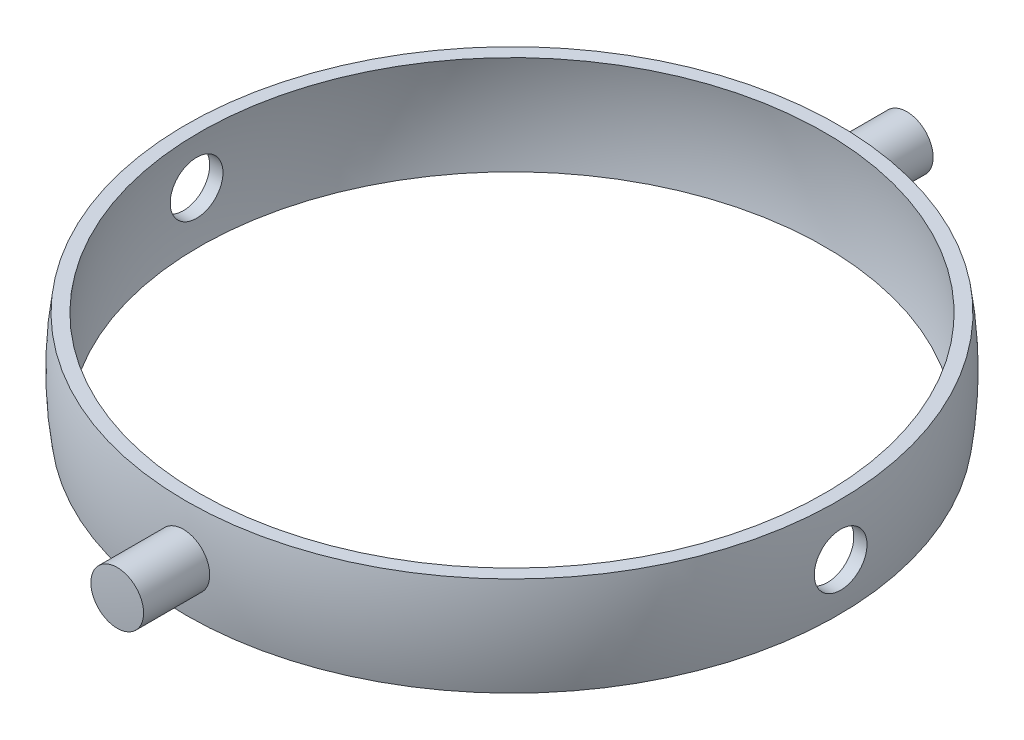
from build123d import *

# Parameters (mm, degrees)
SKETCH2_R               = 4
CUT_EXTRUDE1_DEPTH      = 51
CUT_EXTRUDE1_DEPTH_BACK = 51
SKETCH6_R               = 4
BOSS_EXTRUDE1_DEPTH     = 10.160257


with BuildPart() as part:
    # Sketch1 → Revolve1 (revolve)
    with BuildSketch(Plane.XY):
        with BuildLine():
            Line((-49.434299833, 7.5), (-47.410441888, 7.5))
            ThreePointArc((-47.410441888, 7.5), (-48, 0), (-47.410441888, -7.5))
            Line((-47.410441888, -7.5), (-49.434299833, -7.5))
            ThreePointArc((-49.434299833, -7.5), (-50, 0), (-49.434299833, 7.5))
        make_face()
    revolve(axis=Axis((0, 31.203935911, 0), (0, -1, 0)))

    # Sketch2 → Cut-Extrude1 (cut, two sides)
    with BuildSketch(Plane(origin=(0, 0, 0), x_dir=(0, 0, -1), z_dir=(1, 0, 0))) as cut_extrude1_sk:
        Circle(SKETCH2_R)
    extrude(amount=CUT_EXTRUDE1_DEPTH, mode=Mode.SUBTRACT)
    extrude(cut_extrude1_sk.sketch, amount=-CUT_EXTRUDE1_DEPTH_BACK, mode=Mode.SUBTRACT)

    # Sketch6 → Boss-Extrude1 (add)
    with BuildSketch(Plane.XY.offset(60)):
        Circle(SKETCH6_R)
    boss_extrude1 = extrude(amount=-BOSS_EXTRUDE1_DEPTH)

    # Mirror1: Boss-Extrude1 across plane
    add(boss_extrude1.mirror(Plane.XY))

    # Sketch8 → Cut-Revolve1 (revolve, cut)
    with BuildSketch(Plane(origin=(0, 0, 0), x_dir=(0, 0, -1), z_dir=(1, 0, 0))):
        with BuildLine():
            Line((0, 70), (0, 60))
            ThreePointArc((0, 60), (-60, 0), (0, -60))
            Line((0, -60), (0, -70))
            ThreePointArc((0, -70), (-70, 0), (0, 70))
        make_face()
    revolve(axis=Axis((0, 45.192031549, 0), (0, -1, 0)), mode=Mode.SUBTRACT)


solid = part.part
